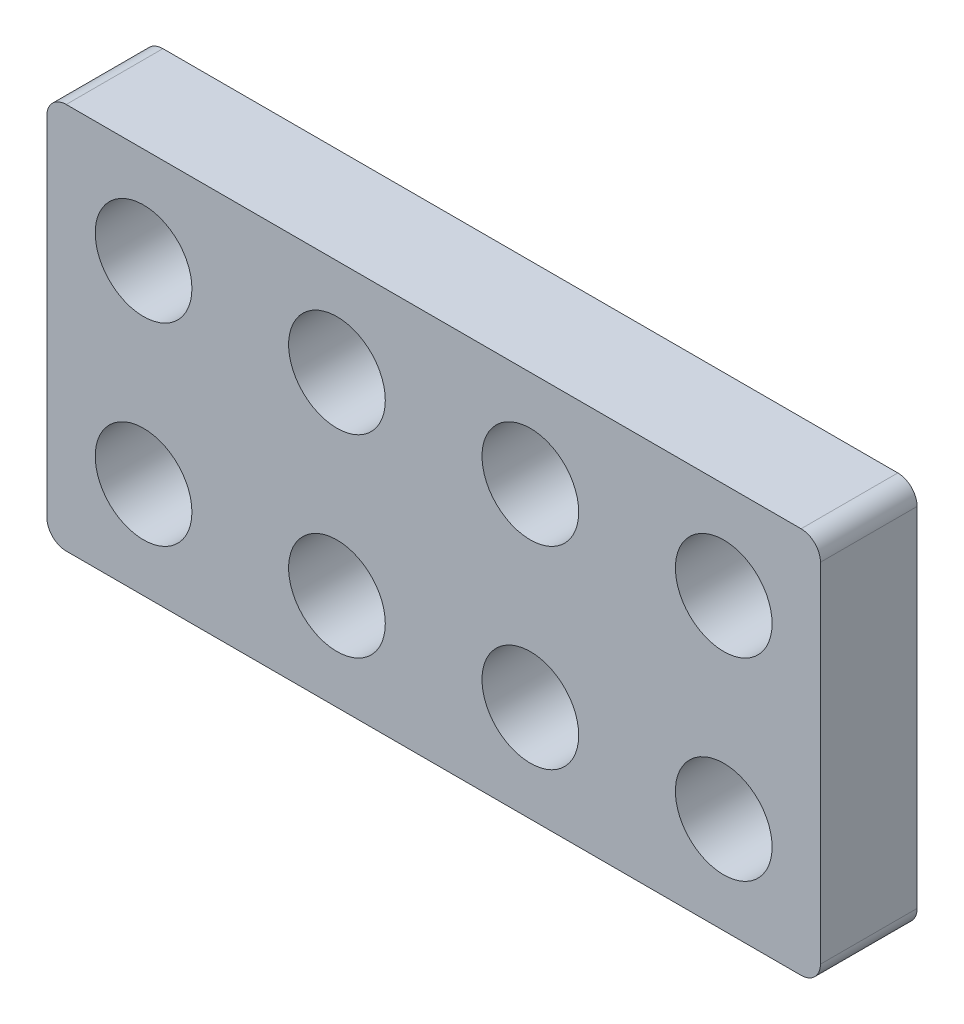
from build123d import *

# Parameters (mm, degrees)
SKETCH2_W            = 80
SKETCH2_H            = 40
BOSS_EXTRUDE2_DEPTH  = 10
SKETCH3_R            = 5
CUT_EXTRUDE1_DEPTH   = 11
LPATTERN2_COUNT      = 4
LPATTERN2_PITCH      = 20
LPATTERN2_COUNT_DIR2 = 2
LPATTERN2_PITCH_DIR2 = 20
FILLET1_R            = 2


with BuildPart() as part:
    # Sketch2 → Boss-Extrude2 (new body)
    with BuildSketch(Plane.XY):
        with Locations((40, 20)):
            Rectangle(SKETCH2_W, SKETCH2_H)
    extrude(amount=BOSS_EXTRUDE2_DEPTH)

    # Sketch3 → Cut-Extrude1 (cut, through all)
    with BuildSketch(Plane.XY.offset(10)):
        with Locations((10, 10)):
            Circle(SKETCH3_R)
    cut_extrude1 = extrude(amount=-CUT_EXTRUDE1_DEPTH, mode=Mode.SUBTRACT)

    # LPattern2: Cut-Extrude1 4 × 2
    with Locations(*[(i * LPATTERN2_PITCH, j * LPATTERN2_PITCH_DIR2, 0) for i in range(LPATTERN2_COUNT) for j in range(LPATTERN2_COUNT_DIR2) if (i, j) != (0, 0)]):
        add(cut_extrude1, mode=Mode.SUBTRACT)

    # Fillet1
    fillet1_edges = [part.edges().sort_by_distance(p)[0] for p in [
        (0, 40, 5),
        (80, 40, 5),
        (80, 0, 5),
        (0, 0, 5),
    ]]
    fillet(fillet1_edges, radius=FILLET1_R)


solid = part.part
